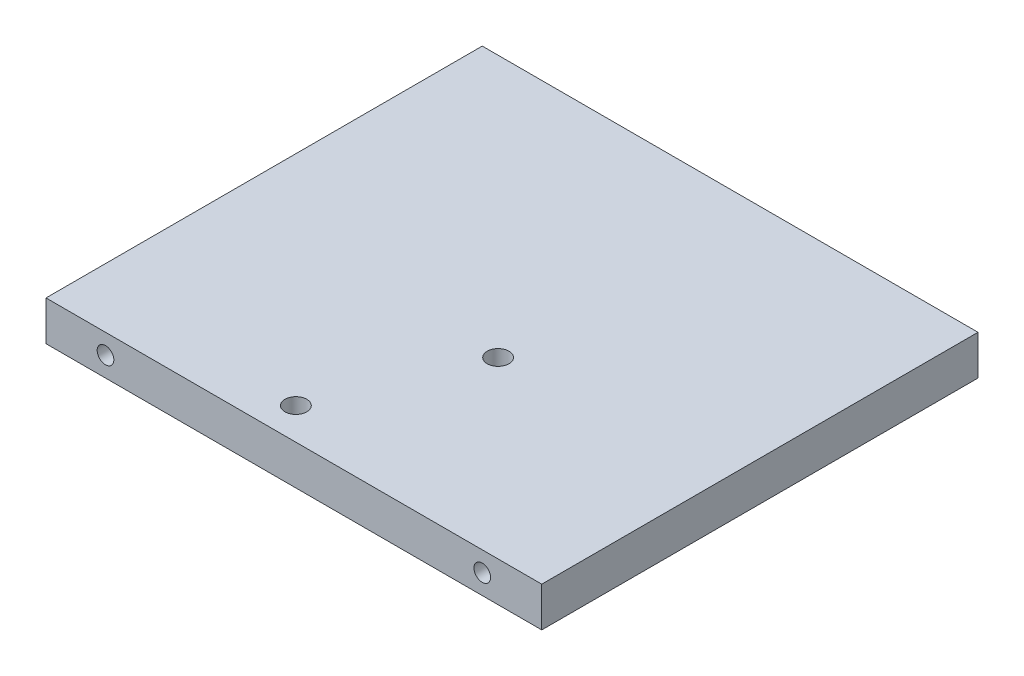
from build123d import *

# Parameters (mm, degrees)
SKETCH1_W             = 125
SKETCH1_H             = 110
SKETCH1_R             = 2.75
BOSS_EXTRUDE1_DEPTH   = 10
M5_TAPPED_HOLE3_D     = 4.2
M5_TAPPED_HOLE3_DEPTH = 16
M5_TAPPED_HOLE3_TIP   = 1.2618073
M5_TAPPED_HOLE4_D     = 4.2
M5_TAPPED_HOLE4_DEPTH = 16
M5_TAPPED_HOLE4_TIP   = 1.2618073
SKETCH13_R            = 5
CUT_EXTRUDE1_DEPTH    = 5.7


with BuildPart() as part:
    # Sketch1 → Boss-Extrude1 (new body)
    with BuildSketch(Plane(origin=(0, 0, 0), x_dir=(1, 0, 0), z_dir=(0, 1, 0))):
        Rectangle(SKETCH1_W, SKETCH1_H)
        with Locations((7.5, -11)):
            Circle(SKETCH1_R, mode=Mode.SUBTRACT)
        with Locations((-7.5, -47)):
            Circle(SKETCH1_R, mode=Mode.SUBTRACT)
    extrude(amount=BOSS_EXTRUDE1_DEPTH)

    # M5 Tapped Hole3
    with Locations(Plane(origin=(0, 0, -55), x_dir=(-1, 0, 0), z_dir=(0, 0, -1))):
        with Locations((-47.5, 5), (47.5, 5)):
            Hole(M5_TAPPED_HOLE3_D / 2, depth=M5_TAPPED_HOLE3_DEPTH)
            with Locations((0, 0, -(M5_TAPPED_HOLE3_DEPTH + M5_TAPPED_HOLE3_TIP / 2))):  # 118° drill point
                Cone(0, M5_TAPPED_HOLE3_D / 2, M5_TAPPED_HOLE3_TIP, mode=Mode.SUBTRACT)

    # M5 Tapped Hole4
    with Locations(Plane.XY.offset(55)):
        with Locations((-47.5, 5), (47.5, 5)):
            Hole(M5_TAPPED_HOLE4_D / 2, depth=M5_TAPPED_HOLE4_DEPTH)
            with Locations((0, 0, -(M5_TAPPED_HOLE4_DEPTH + M5_TAPPED_HOLE4_TIP / 2))):  # 118° drill point
                Cone(0, M5_TAPPED_HOLE4_D / 2, M5_TAPPED_HOLE4_TIP, mode=Mode.SUBTRACT)

    # Sketch13 → Cut-Extrude1 (cut)
    with BuildSketch(Plane(origin=(0, 0, 0), x_dir=(-1, 0, 0), z_dir=(0, -1, 0))):
        with Locations((-7.5, -11)):
            Circle(SKETCH13_R)
        with Locations((7.5, -47)):
            Circle(SKETCH13_R)
    extrude(amount=-CUT_EXTRUDE1_DEPTH, mode=Mode.SUBTRACT)


solid = part.part
